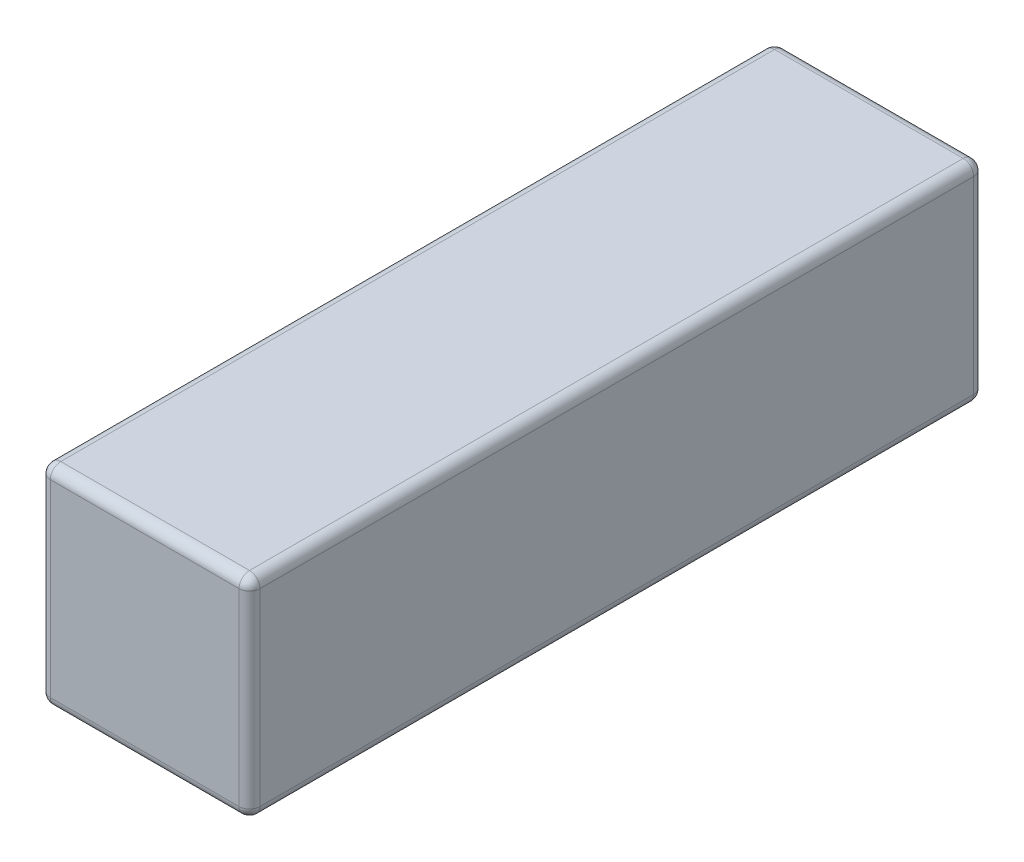
from build123d import *

# Parameters (mm, degrees)
SKETCH1_W           = 25.4
SKETCH1_H           = 25.4
BOSS_EXTRUDE1_DEPTH = 89.0016
FILLET1_R           = 1.27


with BuildPart() as part:
    # Sketch1 → Boss-Extrude1 (new body)
    with BuildSketch(Plane.XY):
        with Locations((12.7, 12.7)):
            Rectangle(SKETCH1_W, SKETCH1_H)
    extrude(amount=BOSS_EXTRUDE1_DEPTH)

    # Fillet1
    fillet1_edges = [part.edges().sort_by_distance(p)[0] for p in [
        (25.4, 12.7, 89.0016),
        (12.7, 25.4, 89.0016),
        (0, 12.7, 89.0016),
        (12.7, 25.4, 0),
        (25.4, 12.7, 0),
        (12.7, 0, 0),
        (0, 12.7, 0),
        (12.7, 0, 89.0016),
        (0, 25.4, 44.5008),
        (25.4, 25.4, 44.5008),
        (25.4, 0, 44.5008),
        (0, 0, 44.5008),
    ]]
    fillet(fillet1_edges, radius=FILLET1_R)


solid = part.part
